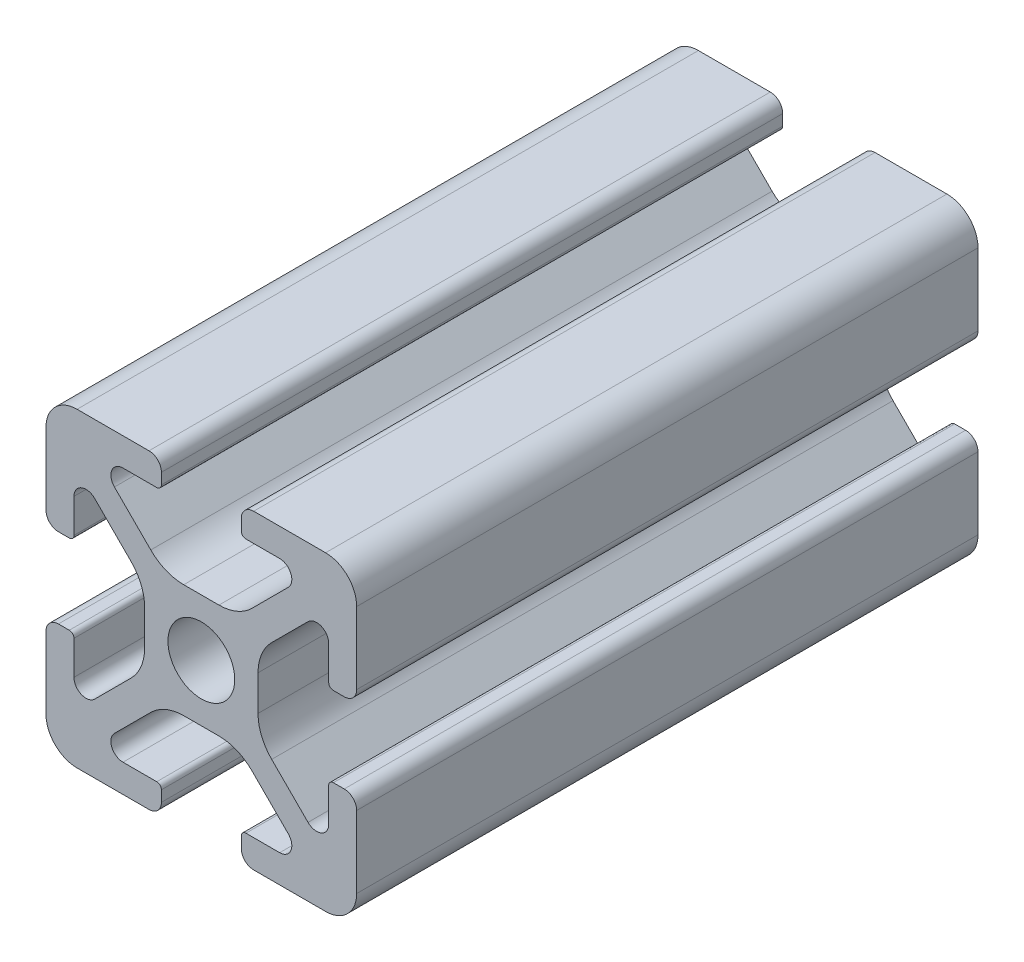
from build123d import *

# Parameters (mm, degrees)
CROQUIS1_R              = 2.15
SALIENTE_EXTRUIR1_DEPTH = 40


with BuildPart() as part:
    # Croquis1 → Saliente-Extruir1 (new body)
    with BuildSketch(Plane.XY):
        with BuildLine():
            Line((3.65, 1.134567107), (3.65, -1.134567107))
            ThreePointArc((3.65, -1.134567107), (3.878361402, -2.282617404), (4.528679656, -3.25588745))
            Line((4.528679656, -3.25588745), (6.868456711, -5.595664505))
            ThreePointArc((6.868456711, -5.595664505), (7.718493077, -5.764747251), (8.2, -5.044121215))
            Line((8.2, -5.044121215), (8.2, -2.87))
            ThreePointArc((8.2, -2.87), (8.287867966, -2.657867966), (8.5, -2.57))
            Line((8.5, -2.57), (9.2, -2.57))
            ThreePointArc((9.2, -2.57), (9.765685425, -2.804314575), (10, -3.37))
            Line((10, -3.37), (10, -8))
            ThreePointArc((10, -8), (9.414213562, -9.414213562), (8, -10))
            Line((8, -10), (3.37, -10))
            ThreePointArc((3.37, -10), (2.804314575, -9.765685425), (2.57, -9.2))
            Line((2.57, -9.2), (2.57, -8.5))
            ThreePointArc((2.57, -8.5), (2.657867966, -8.287867966), (2.87, -8.2))
            Line((2.87, -8.2), (5.044121215, -8.2))
            ThreePointArc((5.044121215, -8.2), (5.764747251, -7.718493077), (5.595664505, -6.868456711))
            Line((5.595664505, -6.868456711), (3.25588745, -4.528679656))
            ThreePointArc((3.25588745, -4.528679656), (2.282617404, -3.878361402), (1.134567107, -3.65))
            Line((1.134567107, -3.65), (-1.134567107, -3.65))
            ThreePointArc((-1.134567107, -3.65), (-2.282617404, -3.878361402), (-3.25588745, -4.528679656))
            Line((-3.25588745, -4.528679656), (-5.595664505, -6.868456711))
            ThreePointArc((-5.595664505, -6.868456711), (-5.764747251, -7.718493077), (-5.044121215, -8.2))
            Line((-5.044121215, -8.2), (-2.87, -8.2))
            ThreePointArc((-2.87, -8.2), (-2.657867966, -8.287867966), (-2.57, -8.5))
            Line((-2.57, -8.5), (-2.57, -9.2))
            ThreePointArc((-2.57, -9.2), (-2.804314575, -9.765685425), (-3.37, -10))
            Line((-3.37, -10), (-8, -10))
            ThreePointArc((-8, -10), (-9.414213562, -9.414213562), (-10, -8))
            Line((-10, -8), (-10, -3.37))
            ThreePointArc((-10, -3.37), (-9.765685425, -2.804314575), (-9.2, -2.57))
            Line((-9.2, -2.57), (-8.5, -2.57))
            ThreePointArc((-8.5, -2.57), (-8.287867966, -2.657867966), (-8.2, -2.87))
            Line((-8.2, -2.87), (-8.2, -5.044121215))
            ThreePointArc((-8.2, -5.044121215), (-7.718493077, -5.764747251), (-6.868456711, -5.595664505))
            Line((-6.868456711, -5.595664505), (-4.528679656, -3.25588745))
            ThreePointArc((-4.528679656, -3.25588745), (-3.878361402, -2.282617404), (-3.65, -1.134567107))
            Line((-3.65, -1.134567107), (-3.65, 1.134567107))
            ThreePointArc((-3.65, 1.134567107), (-3.878361402, 2.282617404), (-4.528679656, 3.25588745))
            Line((-4.528679656, 3.25588745), (-6.868456711, 5.595664505))
            ThreePointArc((-6.868456711, 5.595664505), (-7.718493077, 5.764747251), (-8.2, 5.044121215))
            Line((-8.2, 5.044121215), (-8.2, 2.87))
            ThreePointArc((-8.2, 2.87), (-8.287867966, 2.657867966), (-8.5, 2.57))
            Line((-8.5, 2.57), (-9.2, 2.57))
            ThreePointArc((-9.2, 2.57), (-9.765685425, 2.804314575), (-10, 3.37))
            Line((-10, 3.37), (-10, 8))
            ThreePointArc((-10, 8), (-9.414213562, 9.414213562), (-8, 10))
            Line((-8, 10), (-3.37, 10))
            ThreePointArc((-3.37, 10), (-2.804314575, 9.765685425), (-2.57, 9.2))
            Line((-2.57, 9.2), (-2.57, 8.5))
            ThreePointArc((-2.57, 8.5), (-2.657867966, 8.287867966), (-2.87, 8.2))
            Line((-2.87, 8.2), (-5.044121215, 8.2))
            ThreePointArc((-5.044121215, 8.2), (-5.764747251, 7.718493077), (-5.595664505, 6.868456711))
            Line((-5.595664505, 6.868456711), (-3.25588745, 4.528679656))
            ThreePointArc((-3.25588745, 4.528679656), (-2.282617404, 3.878361402), (-1.134567107, 3.65))
            Line((-1.134567107, 3.65), (1.134567107, 3.65))
            ThreePointArc((1.134567107, 3.65), (2.282617404, 3.878361402), (3.25588745, 4.528679656))
            Line((3.25588745, 4.528679656), (5.595664505, 6.868456711))
            ThreePointArc((5.595664505, 6.868456711), (5.764747251, 7.718493077), (5.044121215, 8.2))
            Line((5.044121215, 8.2), (2.87, 8.2))
            ThreePointArc((2.87, 8.2), (2.657867966, 8.287867966), (2.57, 8.5))
            Line((2.57, 8.5), (2.57, 9.2))
            ThreePointArc((2.57, 9.2), (2.804314575, 9.765685425), (3.37, 10))
            Line((3.37, 10), (8, 10))
            ThreePointArc((8, 10), (9.414213562, 9.414213562), (10, 8))
            Line((10, 8), (10, 3.37))
            ThreePointArc((10, 3.37), (9.765685425, 2.804314575), (9.2, 2.57))
            Line((9.2, 2.57), (8.5, 2.57))
            ThreePointArc((8.5, 2.57), (8.287867966, 2.657867966), (8.2, 2.87))
            Line((8.2, 2.87), (8.2, 5.044121215))
            ThreePointArc((8.2, 5.044121215), (7.718493077, 5.764747251), (6.868456711, 5.595664505))
            Line((6.868456711, 5.595664505), (4.528679656, 3.25588745))
            ThreePointArc((4.528679656, 3.25588745), (3.878361402, 2.282617404), (3.65, 1.134567107))
        make_face()
        Circle(CROQUIS1_R, mode=Mode.SUBTRACT)
    extrude(amount=SALIENTE_EXTRUIR1_DEPTH)


solid = part.part
